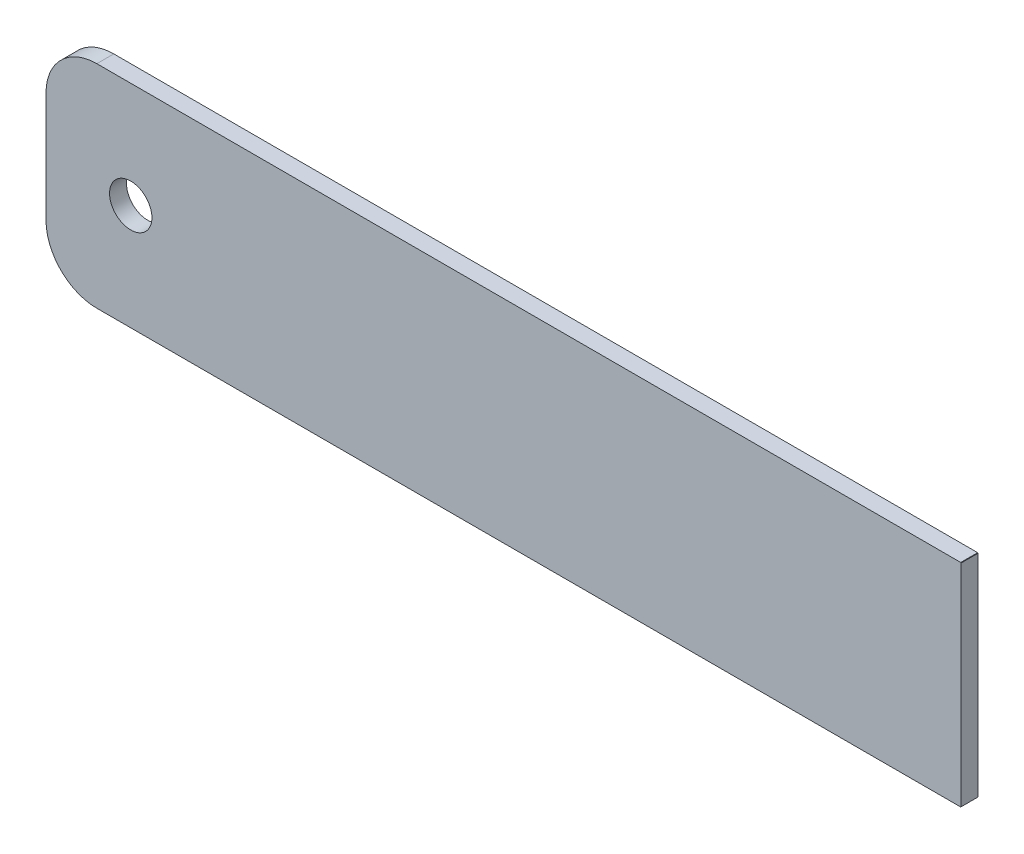
from build123d import *

# Parameters (mm, degrees)
SKETCH1_R      = 1.5875
EXTRUDE1_DEPTH = 1.27


with BuildPart() as part:
    # Sketch1 → Extrude1 (new body)
    with BuildSketch(Plane.XY):
        with BuildLine():
            Line((0, 15.8496), (-0.0254, 15.875))
            Line((-0.0254, 15.875), (-64.77, 15.875))
            ThreePointArc((-64.77, 15.875), (-67.464076836, 14.759076836), (-68.58, 12.065))
            Line((-68.58, 12.065), (-68.58, 3.81))
            ThreePointArc((-68.58, 3.81), (-67.464076836, 1.115923164), (-64.77, 0))
            Line((-64.77, 0), (-0.0254, 0))
            Line((-0.0254, 0), (0, 0.0254))
            Line((0, 0.0254), (0, 15.8496))
        make_face()
        with Locations((-62.23, 7.9375)):
            Circle(SKETCH1_R, mode=Mode.SUBTRACT)
    extrude(amount=EXTRUDE1_DEPTH)


solid = part.part
